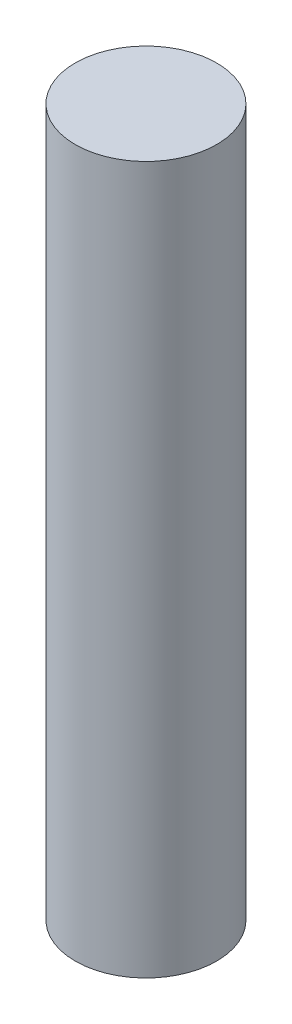
from build123d import *

# Parameters (mm, degrees)
SKETCH1_R           = 1.5
BOSS_EXTRUDE1_DEPTH = 15


with BuildPart() as part:
    # Sketch1 → Boss-Extrude1 (new body)
    with BuildSketch(Plane(origin=(0, 0, 0), x_dir=(1, 0, 0), z_dir=(0, 1, 0))):
        Circle(SKETCH1_R)
    extrude(amount=BOSS_EXTRUDE1_DEPTH)


solid = part.part
